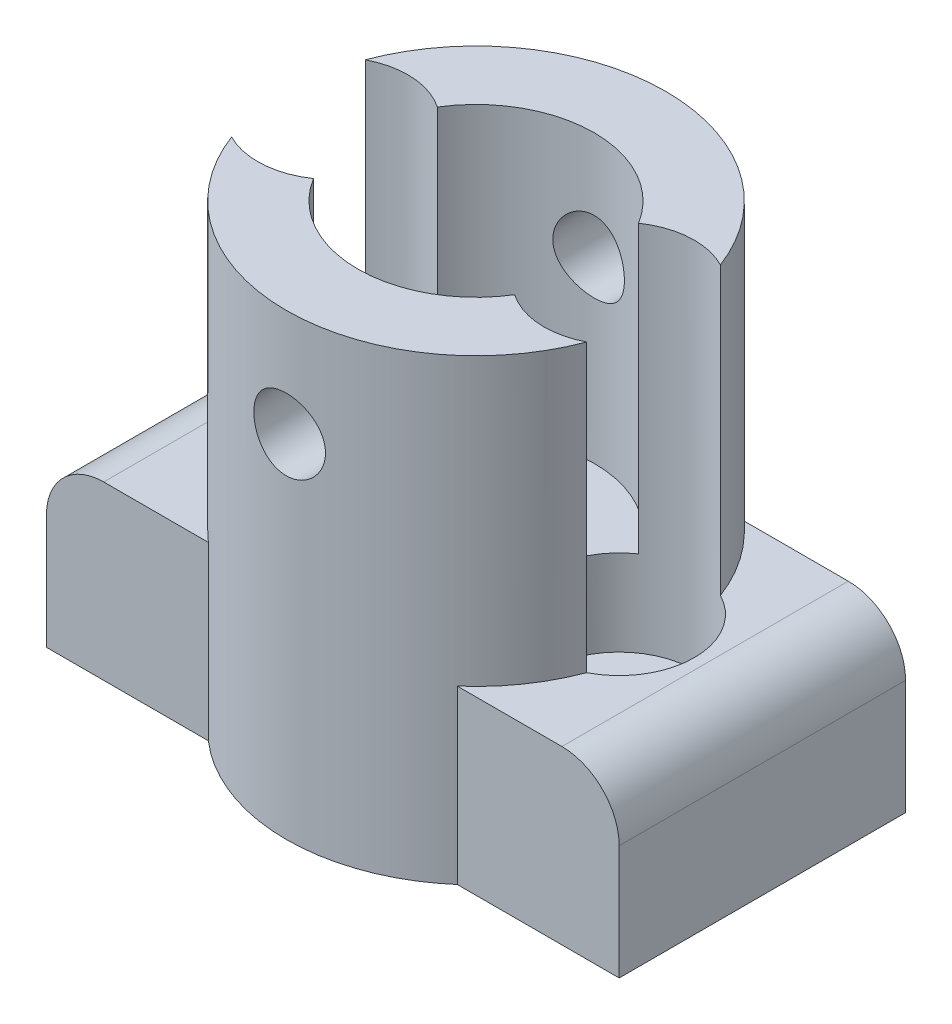
from build123d import *

# Parameters (mm, degrees)
SKETCH1_W                      = 40
SKETCH1_H                      = 20
BOSS_EXTRUDE1_DEPTH            = 12
CBORE_FOR_M5_SHCS1_D           = 5.5
CBORE_FOR_M5_SHCS1_DEPTH       = 12
CBORE_FOR_M5_SHCS1_CBORE_D     = 10.5
CBORE_FOR_M5_SHCS1_CBORE_DEPTH = 6
BOSS_EXTRUDE2_DEPTH            = 20
BOSS_EXTRUDE2_DEPTH_BACK       = 12
SKETCH6_R                      = 2.5
CUT_EXTRUDE1_DEPTH             = 14.25
CUT_EXTRUDE1_DEPTH_BACK        = 14.25
FILLET1_R                      = 4


with BuildPart() as part:
    # Sketch1 → Boss-Extrude1 (new body)
    with BuildSketch(Plane(origin=(0, 0, 0), x_dir=(1, 0, 0), z_dir=(0, 1, 0))):
        Rectangle(SKETCH1_W, SKETCH1_H)
    extrude(amount=BOSS_EXTRUDE1_DEPTH)

    # CBORE for M5 SHCS1
    with Locations(Plane(origin=(0, 12, 0), x_dir=(1, 0, 0), z_dir=(0, 1, 0))):
        with Locations((10, 0), (-10, 0)):
            CounterBoreHole(CBORE_FOR_M5_SHCS1_D / 2, CBORE_FOR_M5_SHCS1_CBORE_D / 2, CBORE_FOR_M5_SHCS1_CBORE_DEPTH, depth=CBORE_FOR_M5_SHCS1_DEPTH)

    # Sketch4 → Boss-Extrude2 (add, two sides)
    with BuildSketch(Plane(origin=(0, 12, 0), x_dir=(1, 0, 0), z_dir=(0, 1, 0))) as boss_extrude2_sk:
        with BuildLine():
            ThreePointArc((-12.4, -4.669314725), (0, -13.25), (12.4, -4.669314725))
            ThreePointArc((12.4, -4.669314725), (9.665081865, -5.239306237), (7.025, -4.325722483))
            ThreePointArc((7.025, -4.325722483), (0, -8.25), (-7.025, -4.325722483))
            ThreePointArc((-7.025, -4.325722483), (-9.665081865, -5.239306237), (-12.4, -4.669314725))
        make_face()
        with BuildLine():
            ThreePointArc((-7.025, 4.325722483), (-9.665081865, 5.239306237), (-12.4, 4.669314725))
            ThreePointArc((-12.4, 4.669314725), (0, 13.25), (12.4, 4.669314725))
            ThreePointArc((12.4, 4.669314725), (9.665081865, 5.239306237), (7.025, 4.325722483))
            ThreePointArc((7.025, 4.325722483), (0, 8.25), (-7.025, 4.325722483))
        make_face()
    extrude(amount=BOSS_EXTRUDE2_DEPTH)
    extrude(boss_extrude2_sk.sketch, amount=-BOSS_EXTRUDE2_DEPTH_BACK)

    # Sketch6 → Cut-Extrude1 (cut, two sides)
    with BuildSketch(Plane.XY) as cut_extrude1_sk:
        with Locations((0, 24.5)):
            Circle(SKETCH6_R)
    extrude(amount=CUT_EXTRUDE1_DEPTH, mode=Mode.SUBTRACT)
    extrude(cut_extrude1_sk.sketch, amount=-CUT_EXTRUDE1_DEPTH_BACK, mode=Mode.SUBTRACT)

    # Fillet1
    fillet1_edges = [part.edges().sort_by_distance(p)[0] for p in [
        (-20, 12, 0),
        (20, 12, 0),
    ]]
    fillet(fillet1_edges, radius=FILLET1_R)


solid = part.part
